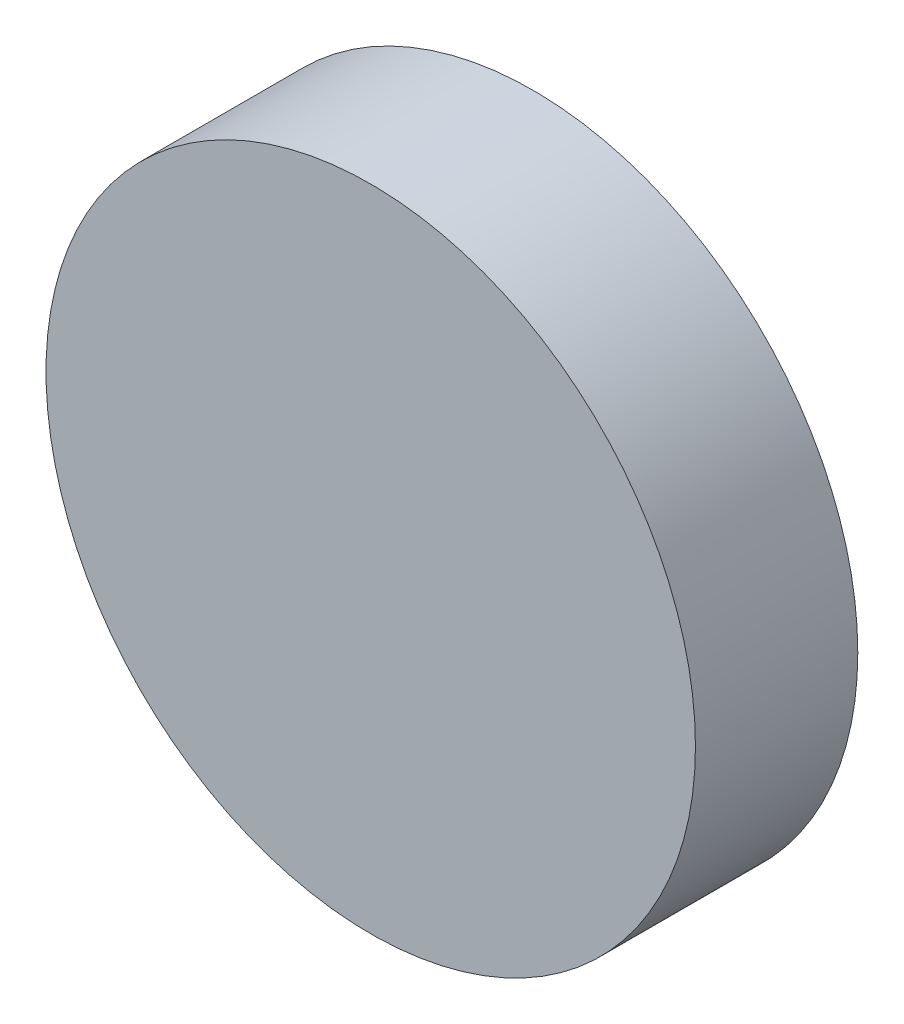
from build123d import *

# Parameters (mm, degrees)
SKETCH1_R           = 12.7
BOSS_EXTRUDE1_DEPTH = 6.35


with BuildPart() as part:
    # Sketch1 → Boss-Extrude1 (new body)
    with BuildSketch(Plane.XY):
        Circle(SKETCH1_R)
    extrude(amount=BOSS_EXTRUDE1_DEPTH)


solid = part.part
